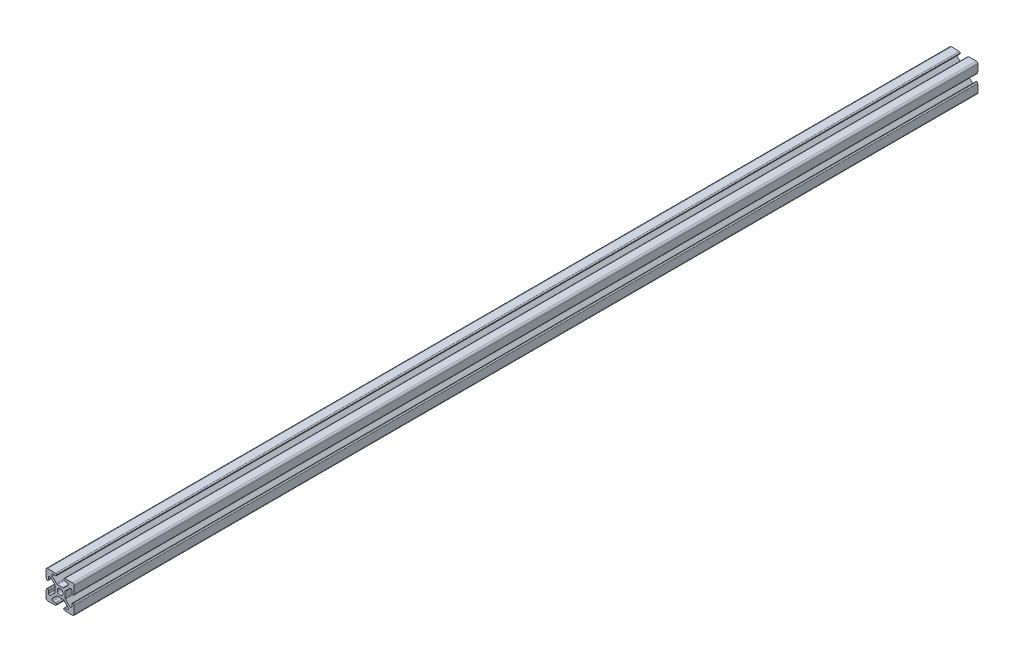
from build123d import *

# Parameters (mm, degrees)
SKETCH1_R      = 2.5527
EXTRUDE1_DEPTH = 812.8


with BuildPart() as part:
    # Sketch1 → Extrude1 (new body)
    with BuildSketch(Plane.XY):
        with BuildLine():
            Line((3.238504286, -11.455400345), (3.238504286, -11.49073383))
            ThreePointArc((3.238504286, -11.49073383), (3.509397472, -12.161218003), (4.170019162, -12.455345741))
            Line((4.170019162, -12.455345741), (11.176001705, -12.7))
            ThreePointArc((11.176001705, -12.7), (12.253632411, -12.253630746), (12.700001664, -11.17600004))
            Line((12.700001664, -11.17600004), (12.455347406, -4.170014669))
            ThreePointArc((12.455347406, -4.170014669), (12.16121968, -3.509392954), (11.490735494, -3.238499755))
            Line((11.490735494, -3.238499755), (11.455402009, -3.238499755))
            ThreePointArc((11.455402009, -3.238499755), (10.772902626, -3.521200256), (10.490202125, -4.20369964))
            Line((10.490202125, -4.20369964), (10.490202125, -6.352134987))
            ThreePointArc((10.490202125, -6.352134987), (9.831646779, -7.337732713), (8.669054992, -7.106478829))
            Line((8.669054992, -7.106478829), (4.820959759, -3.258383596))
            ThreePointArc((4.820959759, -3.258383596), (4.589705874, -2.912287699), (4.508500309, -2.504039754))
            Line((4.508500309, -2.504039754), (4.508500309, 2.504040946))
            ThreePointArc((4.508500309, 2.504040946), (4.589705874, 2.912288891), (4.820959759, 3.258384788))
            Line((4.820959759, 3.258384788), (8.669054992, 7.106480021))
            ThreePointArc((8.669054992, 7.106480021), (9.831646779, 7.337733906), (10.490202125, 6.35213618))
            Line((10.490202125, 6.35213618), (10.490202125, 4.203700832))
            ThreePointArc((10.490202125, 4.203700832), (10.772902626, 3.521201448), (11.455402009, 3.238500947))
            Line((11.455402009, 3.238500947), (11.490735494, 3.238500947))
            ThreePointArc((11.490735494, 3.238500947), (12.161219667, 3.509394133), (12.455347406, 4.170015823))
            Line((12.455347406, 4.170015823), (12.700001664, 11.176000039))
            ThreePointArc((12.700001664, 11.176000039), (12.253632411, 12.253630745), (11.176001705, 12.699999999))
            Line((11.176001705, 12.699999999), (4.170019162, 12.455345462))
            ThreePointArc((4.170019162, 12.455345462), (3.509397447, 12.161217736), (3.238504248, 11.49073355))
            Line((3.238504248, 11.49073355), (3.238504248, 11.455400065))
            ThreePointArc((3.238504248, 11.455400065), (3.521204749, 10.772900682), (4.203704132, 10.490200181))
            Line((4.203704132, 10.490200181), (6.35213948, 10.490200181))
            ThreePointArc((6.35213948, 10.490200181), (7.337737205, 9.831644835), (7.106483322, 8.669053049))
            Line((7.106483322, 8.669053049), (3.258388088, 4.820957816))
            ThreePointArc((3.258388088, 4.820957816), (2.912292192, 4.589703931), (2.504044247, 4.508498366))
            Line((2.504044247, 4.508498366), (-2.504036453, 4.508498366))
            ThreePointArc((-2.504036453, 4.508498366), (-2.912284398, 4.589703931), (-3.258380295, 4.820957816))
            Line((-3.258380295, 4.820957816), (-7.106475528, 8.669053049))
            ThreePointArc((-7.106475528, 8.669053049), (-7.337729412, 9.831644836), (-6.352131686, 10.490200182))
            Line((-6.352131686, 10.490200182), (-4.203696339, 10.490200182))
            ThreePointArc((-4.203696339, 10.490200182), (-3.521196955, 10.772900683), (-3.238496454, 11.455400067))
            Line((-3.238496454, 11.455400067), (-3.238496454, 11.490733551))
            ThreePointArc((-3.238496454, 11.490733551), (-3.50938964, 12.161217724), (-4.17001133, 12.455345462))
            Line((-4.17001133, 12.455345462), (-11.175998375, 12.699999999))
            ThreePointArc((-11.175998375, 12.699999999), (-12.253629081, 12.253630745), (-12.699998335, 11.176000039))
            Line((-12.699998335, 11.176000039), (-12.455343798, 4.170015823))
            ThreePointArc((-12.455343798, 4.170015823), (-12.161216073, 3.509394108), (-11.490731887, 3.238500909))
            Line((-11.490731887, 3.238500909), (-11.455398403, 3.238500909))
            ThreePointArc((-11.455398403, 3.238500909), (-10.772899019, 3.52120141), (-10.490198518, 4.203700793))
            Line((-10.490198518, 4.203700793), (-10.490198518, 6.352136141))
            ThreePointArc((-10.490198518, 6.352136141), (-9.831643172, 7.337733867), (-8.669051385, 7.106479983))
            Line((-8.669051385, 7.106479983), (-4.820956152, 3.258384749))
            ThreePointArc((-4.820956152, 3.258384749), (-4.589702267, 2.912288853), (-4.508496702, 2.504040908))
            Line((-4.508496702, 2.504040908), (-4.508496702, -2.504039793))
            ThreePointArc((-4.508496702, -2.504039793), (-4.589702267, -2.912287738), (-4.820956152, -3.258383634))
            Line((-4.820956152, -3.258383634), (-8.669051385, -7.106478867))
            ThreePointArc((-8.669051385, -7.106478867), (-9.831643172, -7.337732752), (-10.490198518, -6.352135026))
            Line((-10.490198518, -6.352135026), (-10.490198518, -4.203699678))
            ThreePointArc((-10.490198518, -4.203699678), (-10.772899019, -3.521200294), (-11.455398403, -3.238499793))
            Line((-11.455398403, -3.238499793), (-11.490731887, -3.238499793))
            ThreePointArc((-11.490731887, -3.238499793), (-12.16121606, -3.509392979), (-12.455343798, -4.170014669))
            Line((-12.455343798, -4.170014669), (-12.699998335, -11.17600004))
            ThreePointArc((-12.699998335, -11.17600004), (-12.253629081, -12.253630746), (-11.175998375, -12.7))
            Line((-11.175998375, -12.7), (-4.17001133, -12.455345741))
            ThreePointArc((-4.17001133, -12.455345741), (-3.509389615, -12.161218016), (-3.238496416, -11.49073383))
            Line((-3.238496416, -11.49073383), (-3.238496416, -11.455400345))
            ThreePointArc((-3.238496416, -11.455400345), (-3.521196917, -10.772900961), (-4.2036963, -10.49020046))
            Line((-4.2036963, -10.49020046), (-6.352131648, -10.49020046))
            ThreePointArc((-6.352131648, -10.49020046), (-7.337729374, -9.831645114), (-7.106475489, -8.669053328))
            Line((-7.106475489, -8.669053328), (-3.258380256, -4.820958094))
            ThreePointArc((-3.258380256, -4.820958094), (-2.91228436, -4.58970421), (-2.504036415, -4.508498645))
            Line((-2.504036415, -4.508498645), (2.504044285, -4.508498645))
            ThreePointArc((2.504044285, -4.508498645), (2.91229223, -4.58970421), (3.258388127, -4.820958094))
            Line((3.258388127, -4.820958094), (7.10648336, -8.669053328))
            ThreePointArc((7.10648336, -8.669053328), (7.337737245, -9.831645114), (6.352139519, -10.49020046))
            Line((6.352139519, -10.49020046), (4.203704171, -10.49020046))
            ThreePointArc((4.203704171, -10.49020046), (3.521204787, -10.772900961), (3.238504286, -11.455400345))
        make_face()
        Circle(SKETCH1_R, mode=Mode.SUBTRACT)
    extrude(amount=EXTRUDE1_DEPTH)


solid = part.part
